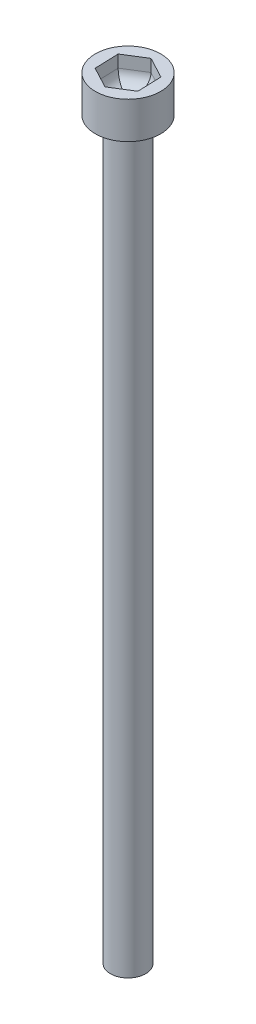
from build123d import *

# Parameters (mm, degrees)
CUT_EXTRUDE1_DEPTH = 2
FILLET1_R          = 1


with BuildPart() as part:
    # Sketch1 → Revolve2 (revolve)
    with BuildSketch(Plane.XY):
        Polygon((0, 0), (1.44, 0), (1.44, 60), (2.665, 60), (2.665, 63), (0, 63), align=None)
    revolve(axis=Axis((0, 0, 0), (0, 1, 0)))

    # Sketch3 → Cut-Extrude1 (cut)
    with BuildSketch(Plane(origin=(0, 63, 0), x_dir=(1, 0, 0), z_dir=(0, 1, 0))):
        Polygon((1.720029198, -0.914625258), (1.652103308, 1.032276352), (-0.067925891, 1.94690161), (-1.720029198, 0.914625258), (-1.652103308, -1.032276352), (0.067925891, -1.94690161), align=None)
    extrude(amount=-CUT_EXTRUDE1_DEPTH, mode=Mode.SUBTRACT)

    # Fillet1
    fillet1_edges = [part.edges().sort_by_distance(p)[0] for p in [
        (0.893977545, 61, 1.430763434),
        (-0.792088708, 61, 1.489588981),
        (-1.686066253, 61, 0.058825547),
        (-0.893977545, 61, -1.430763434),
        (0.792088708, 61, -1.489588981),
        (1.686066253, 61, -0.058825547),
    ]]
    fillet(fillet1_edges, radius=FILLET1_R)


solid = part.part
